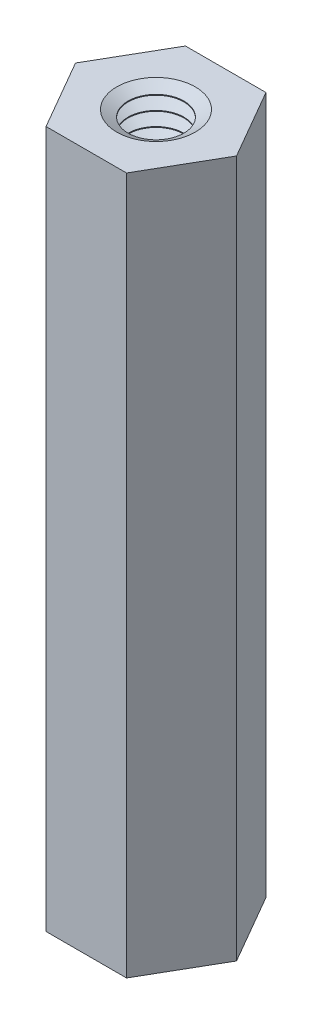
from build123d import *

# Parameters (mm, degrees)
BOSS_EXTRUDE1_DEPTH = 10
SKETCH3_R           = 0.8
CUT_EXTRUDE1_DEPTH  = 20
LPATTERN3_COUNT     = 15
LPATTERN3_PITCH     = 0.4


with BuildPart() as part:
    # Sketch1 → Boss-Extrude1 (new body, symmetric)
    with BuildSketch(Plane(origin=(0, 0, 0), x_dir=(1, 0, 0), z_dir=(0, 1, 0))):
        Polygon((2.309401077, 0), (1.154700538, 2), (-1.154700538, 2), (-2.309401077, 0), (-1.154700538, -2), (1.154700538, -2), align=None)
    extrude(amount=BOSS_EXTRUDE1_DEPTH, both=True)

    # Sketch3 → Cut-Extrude1 (cut)
    with BuildSketch(Plane.XZ.offset(10)):
        Circle(SKETCH3_R)
    extrude(amount=-CUT_EXTRUDE1_DEPTH, mode=Mode.SUBTRACT)

    # Sketch5 → Cut-Revolve3 (revolve, cut)
    with BuildSketch(Plane.XY):
        Polygon((0.38, -9.8), (0.38, -10.2), (0.78, -10.2), (1.126410162, -10), (0.78, -9.8), align=None)
    cut_revolve3 = revolve(axis=Axis((0, 0, 0), (0, -1, 0)), mode=Mode.SUBTRACT)

    # LPattern3: Cut-Revolve3 ×15
    with Locations(*[(0, i * LPATTERN3_PITCH, 0) for i in range(1, LPATTERN3_COUNT)]):
        add(cut_revolve3, mode=Mode.SUBTRACT)

    # Mirror2: Cut-Revolve3 across plane
    add(cut_revolve3.mirror(Plane.ZX), mode=Mode.SUBTRACT)

    # Mirror2 copy 1 sketch → Mirror2 copy 1 (revolve, cut)
    with BuildSketch(Plane(origin=(0, -0.4, 0), x_dir=(1, 0, 0), z_dir=(0, 0, 1))):
        Polygon((0.38, 9.8), (0.38, 10.2), (0.78, 10.2), (1.126410162, 10), (0.78, 9.8), align=None)
    revolve(axis=Axis((0, -0.4, 0), (0, -1, 0)), mode=Mode.SUBTRACT)

    # Mirror2 copy 2 sketch → Mirror2 copy 2 (revolve, cut)
    with BuildSketch(Plane(origin=(0, -0.8, 0), x_dir=(1, 0, 0), z_dir=(0, 0, 1))):
        Polygon((0.38, 9.8), (0.38, 10.2), (0.78, 10.2), (1.126410162, 10), (0.78, 9.8), align=None)
    revolve(axis=Axis((0, -0.8, 0), (0, -1, 0)), mode=Mode.SUBTRACT)

    # Mirror2 copy 3 sketch → Mirror2 copy 3 (revolve, cut)
    with BuildSketch(Plane(origin=(0, -1.2, 0), x_dir=(1, 0, 0), z_dir=(0, 0, 1))):
        Polygon((0.38, 9.8), (0.38, 10.2), (0.78, 10.2), (1.126410162, 10), (0.78, 9.8), align=None)
    revolve(axis=Axis((0, -1.2, 0), (0, -1, 0)), mode=Mode.SUBTRACT)

    # Mirror2 copy 4 sketch → Mirror2 copy 4 (revolve, cut)
    with BuildSketch(Plane(origin=(0, -1.6, 0), x_dir=(1, 0, 0), z_dir=(0, 0, 1))):
        Polygon((0.38, 9.8), (0.38, 10.2), (0.78, 10.2), (1.126410162, 10), (0.78, 9.8), align=None)
    revolve(axis=Axis((0, -1.6, 0), (0, -1, 0)), mode=Mode.SUBTRACT)

    # Mirror2 copy 5 sketch → Mirror2 copy 5 (revolve, cut)
    with BuildSketch(Plane(origin=(0, -2, 0), x_dir=(1, 0, 0), z_dir=(0, 0, 1))):
        Polygon((0.38, 9.8), (0.38, 10.2), (0.78, 10.2), (1.126410162, 10), (0.78, 9.8), align=None)
    revolve(axis=Axis((0, -2, 0), (0, -1, 0)), mode=Mode.SUBTRACT)

    # Mirror2 copy 6 sketch → Mirror2 copy 6 (revolve, cut)
    with BuildSketch(Plane(origin=(0, -2.4, 0), x_dir=(1, 0, 0), z_dir=(0, 0, 1))):
        Polygon((0.38, 9.8), (0.38, 10.2), (0.78, 10.2), (1.126410162, 10), (0.78, 9.8), align=None)
    revolve(axis=Axis((0, -2.4, 0), (0, -1, 0)), mode=Mode.SUBTRACT)

    # Mirror2 copy 7 sketch → Mirror2 copy 7 (revolve, cut)
    with BuildSketch(Plane(origin=(0, -2.8, 0), x_dir=(1, 0, 0), z_dir=(0, 0, 1))):
        Polygon((0.38, 9.8), (0.38, 10.2), (0.78, 10.2), (1.126410162, 10), (0.78, 9.8), align=None)
    revolve(axis=Axis((0, -2.8, 0), (0, -1, 0)), mode=Mode.SUBTRACT)

    # Mirror2 copy 8 sketch → Mirror2 copy 8 (revolve, cut)
    with BuildSketch(Plane(origin=(0, -3.2, 0), x_dir=(1, 0, 0), z_dir=(0, 0, 1))):
        Polygon((0.38, 9.8), (0.38, 10.2), (0.78, 10.2), (1.126410162, 10), (0.78, 9.8), align=None)
    revolve(axis=Axis((0, -3.2, 0), (0, -1, 0)), mode=Mode.SUBTRACT)

    # Mirror2 copy 9 sketch → Mirror2 copy 9 (revolve, cut)
    with BuildSketch(Plane(origin=(0, -3.6, 0), x_dir=(1, 0, 0), z_dir=(0, 0, 1))):
        Polygon((0.38, 9.8), (0.38, 10.2), (0.78, 10.2), (1.126410162, 10), (0.78, 9.8), align=None)
    revolve(axis=Axis((0, -3.6, 0), (0, -1, 0)), mode=Mode.SUBTRACT)

    # Mirror2 copy 10 sketch → Mirror2 copy 10 (revolve, cut)
    with BuildSketch(Plane(origin=(0, -4, 0), x_dir=(1, 0, 0), z_dir=(0, 0, 1))):
        Polygon((0.38, 9.8), (0.38, 10.2), (0.78, 10.2), (1.126410162, 10), (0.78, 9.8), align=None)
    revolve(axis=Axis((0, -4, 0), (0, -1, 0)), mode=Mode.SUBTRACT)

    # Mirror2 copy 11 sketch → Mirror2 copy 11 (revolve, cut)
    with BuildSketch(Plane(origin=(0, -4.4, 0), x_dir=(1, 0, 0), z_dir=(0, 0, 1))):
        Polygon((0.38, 9.8), (0.38, 10.2), (0.78, 10.2), (1.126410162, 10), (0.78, 9.8), align=None)
    revolve(axis=Axis((0, -4.4, 0), (0, -1, 0)), mode=Mode.SUBTRACT)

    # Mirror2 copy 12 sketch → Mirror2 copy 12 (revolve, cut)
    with BuildSketch(Plane(origin=(0, -4.8, 0), x_dir=(1, 0, 0), z_dir=(0, 0, 1))):
        Polygon((0.38, 9.8), (0.38, 10.2), (0.78, 10.2), (1.126410162, 10), (0.78, 9.8), align=None)
    revolve(axis=Axis((0, -4.8, 0), (0, -1, 0)), mode=Mode.SUBTRACT)

    # Mirror2 copy 13 sketch → Mirror2 copy 13 (revolve, cut)
    with BuildSketch(Plane(origin=(0, -5.2, 0), x_dir=(1, 0, 0), z_dir=(0, 0, 1))):
        Polygon((0.38, 9.8), (0.38, 10.2), (0.78, 10.2), (1.126410162, 10), (0.78, 9.8), align=None)
    revolve(axis=Axis((0, -5.2, 0), (0, -1, 0)), mode=Mode.SUBTRACT)

    # Mirror2 copy 14 sketch → Mirror2 copy 14 (revolve, cut)
    with BuildSketch(Plane(origin=(0, -5.6, 0), x_dir=(1, 0, 0), z_dir=(0, 0, 1))):
        Polygon((0.38, 9.8), (0.38, 10.2), (0.78, 10.2), (1.126410162, 10), (0.78, 9.8), align=None)
    revolve(axis=Axis((0, -5.6, 0), (0, -1, 0)), mode=Mode.SUBTRACT)


solid = part.part
